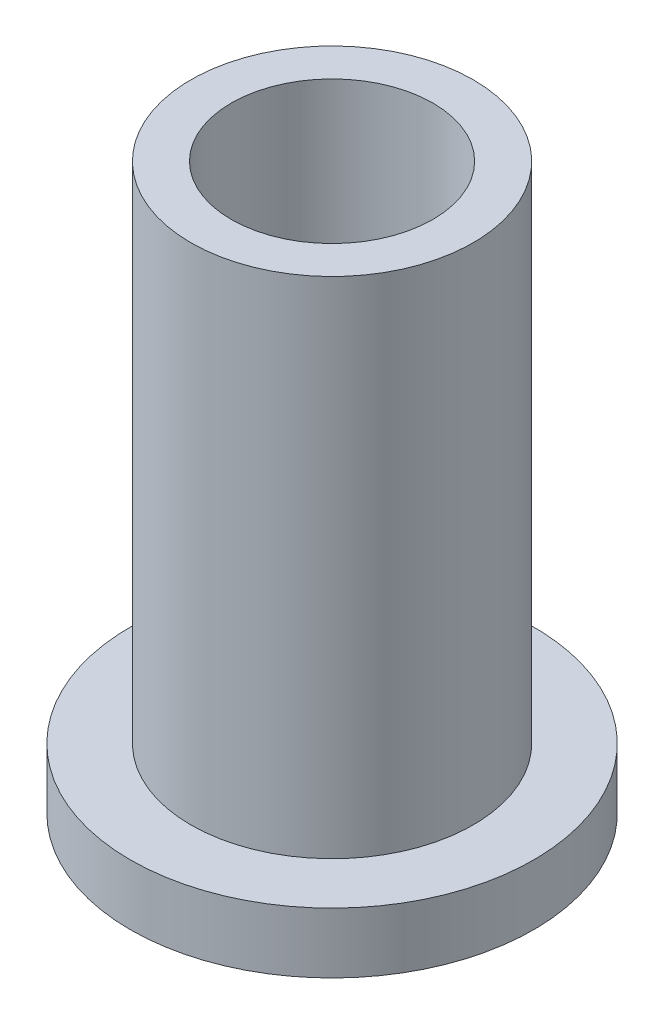
from build123d import *

# Parameters (mm, degrees)
SKETCH1_R           = 5
BOSS_EXTRUDE1_DEPTH = 1.5
SKETCH2_R           = 3.5
BOSS_EXTRUDE2_DEPTH = 12.5
SKETCH3_R           = 2.5
CUT_EXTRUDE1_DEPTH  = 15


with BuildPart() as part:
    # Sketch1 → Boss-Extrude1 (new body)
    with BuildSketch(Plane(origin=(0, 0, 0), x_dir=(1, 0, 0), z_dir=(0, 1, 0))):
        Circle(SKETCH1_R)
    extrude(amount=BOSS_EXTRUDE1_DEPTH)

    # Sketch2 → Boss-Extrude2 (add)
    with BuildSketch(Plane(origin=(0, 1.5, 0), x_dir=(1, 0, 0), z_dir=(0, 1, 0))):
        Circle(SKETCH2_R)
    extrude(amount=BOSS_EXTRUDE2_DEPTH)

    # Sketch3 → Cut-Extrude1 (cut, through all)
    with BuildSketch(Plane(origin=(0, 14, 0), x_dir=(1, 0, 0), z_dir=(0, 1, 0))):
        Circle(SKETCH3_R)
    extrude(amount=-CUT_EXTRUDE1_DEPTH, mode=Mode.SUBTRACT)


solid = part.part
